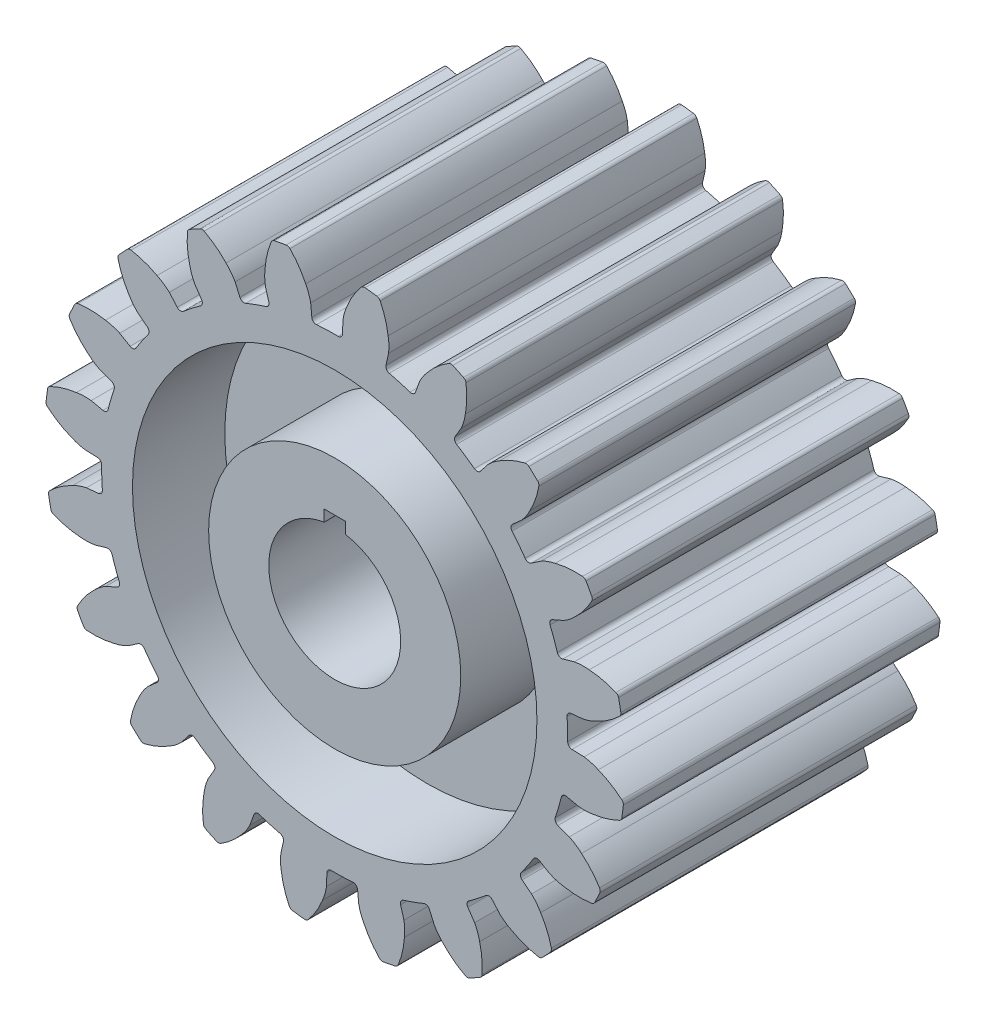
from build123d import *

# Parameters (mm, degrees)
RESSALTO_EXTRUS_O1_DEPTH = 60
PADR_OCIRCULAR1_COUNT    = 20
CORTE_EXTRUS_O1_DEPTH    = 120
ESBO_O3_R                = 76.652725863
ESBO_O3_R_2              = 47.779620373
CORTE_EXTRUS_O2_DEPTH    = 35
ESBO_O4_R                = 76.652725863
ESBO_O4_R_2              = 47.779620373
CORTE_EXTRUS_O3_DEPTH    = 35


with BuildPart() as part:
    # Esboço1 → Ressalto-extrusão1 (new body, symmetric)
    with BuildSketch(Plane.XY):
        with BuildLine():
            Line((32.163809347, 88.912741047), (30.610243685, 84.618107291))
            ThreePointArc((30.610243685, 84.618107291), (29.762582945, 83.68069235), (28.500987004, 83.605517998))
            ThreePointArc((28.500987004, 83.605517998), (-37.580796919, -79.936678709), (46.198669343, 75.285269814))
            ThreePointArc((46.198669343, 75.285269814), (45.451698875, 76.304735666), (45.632784924, 77.555528752))
            Line((45.632784924, 77.555528752), (47.948791566, 81.491714546))
            ThreePointArc((47.948791566, 81.491714546), (48.932718005, 84.127990539), (49.514329457, 86.881132465))
            ThreePointArc((49.514329457, 86.881132465), (50.059923182, 92.081531669), (49.751305764, 97.301357306))
            ThreePointArc((49.751305764, 97.301357306), (49.451372601, 98.04510849), (48.839312997, 98.563286806))
            ThreePointArc((48.839312997, 98.563286806), (46.800494295, 99.547545092), (44.741850957, 100.489635152))
            ThreePointArc((44.741850957, 100.489635152), (43.95234641, 100.630377104), (43.188263859, 100.386853839))
            ThreePointArc((43.188263859, 100.386853839), (38.971786754, 97.294420295), (35.315229616, 93.556584788))
            ThreePointArc((35.315229616, 93.556584788), (33.566190194, 91.3522882), (32.163809347, 88.912741047))
        make_face()
    ressalto_extrus_o1 = extrude(amount=RESSALTO_EXTRUS_O1_DEPTH, both=True)

    # PadrãoCircular1: Ressalto-extrusão1 ×20 about axis
    padr_ocircular1_axis = Axis((0, 0, 0), (0, 0, 1))
    for i in range(1, PADR_OCIRCULAR1_COUNT):
        add(ressalto_extrus_o1.rotate(padr_ocircular1_axis, i * 360 / PADR_OCIRCULAR1_COUNT))

    # Esboço2 → Corte-extrusão1 (cut)
    with BuildSketch(Plane.XY.offset(60)):
        with BuildLine():
            Line((4, 24.677925359), (4, 29))
            Line((4, 29), (-4, 29))
            Line((-4, 29), (-4, 24.677925359))
            ThreePointArc((-4, 24.677925359), (0, -25), (4, 24.677925359))
        make_face()
    extrude(amount=-CORTE_EXTRUS_O1_DEPTH, mode=Mode.SUBTRACT)

    # Esboço3 → Corte-extrusão2 (cut)
    with BuildSketch(Plane.XY.offset(60)):
        Circle(ESBO_O3_R)
        Circle(ESBO_O3_R_2, mode=Mode.SUBTRACT)
    extrude(amount=-CORTE_EXTRUS_O2_DEPTH, mode=Mode.SUBTRACT)

    # Esboço4 → Corte-extrusão3 (cut)
    with BuildSketch(Plane(origin=(0, 0, -60), x_dir=(-1, 0, 0), z_dir=(0, 0, -1))):
        Circle(ESBO_O4_R)
        Circle(ESBO_O4_R_2, mode=Mode.SUBTRACT)
    extrude(amount=-CORTE_EXTRUS_O3_DEPTH, mode=Mode.SUBTRACT)


solid = part.part
